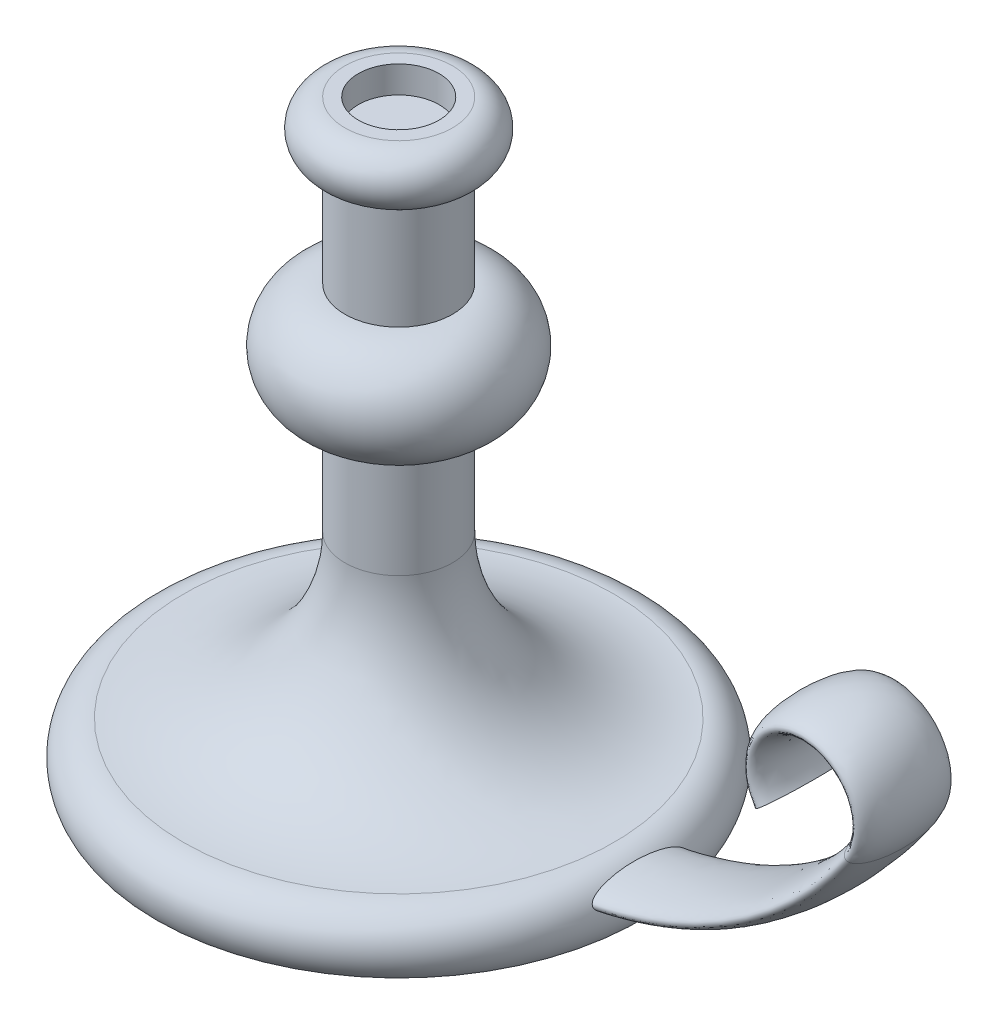
from build123d import *

# Parameters (mm, degrees)
SKETCH5_RX         = 17.5
SKETCH5_RY         = 5
SKETCH6_R          = 15
CUT_EXTRUDE1_DEPTH = 10


with BuildPart() as part:
    # Sketch1 → Revolve1 (revolve)
    with BuildSketch(Plane.XY):
        with BuildLine():
            Line((0, 0), (90, 0))
            ThreePointArc((90, 0), (91.180339887, 13.090169944), (80, 20))
            ThreePointArc((80, 20), (37.573593129, 37.573593129), (20, 80))
            Line((20, 80), (20, 120))
            ThreePointArc((20, 120), (40, 140), (20, 160))
            Line((20, 160), (20, 200))
            ThreePointArc((20, 200), (30, 210), (20, 220))
            Line((20, 220), (0, 220))
            Line((0, 220), (0, 0))
        make_face()
    revolve(axis=Axis((0, 0, 0), (0, 1, 0)))

    # Sweep1: sweep along a path in Sketch2
    with BuildLine(Plane.XY) as sweep1_path:
        Line((0, 10), (60, 10))
        ThreePointArc((60, 10), (129.821200219, 27.240819526), (183.592070943, 75))
        ThreePointArc((183.592070943, 75), (167.113128151, 106.333333333), (150.634185358, 75))
    # Sketch5 → Sweep1 (sweep)
    with BuildSketch(Plane(origin=(0, 0, 0), x_dir=(0, 0, -1), z_dir=(1, 0, 0))):
        with Locations(Location((0, 10), (0, 0, 180))):
            Ellipse(SKETCH5_RX, SKETCH5_RY)
    sweep(path=sweep1_path.line)

    # Sketch6 → Cut-Extrude1 (cut)
    with BuildSketch(Plane(origin=(0, 220, 0), x_dir=(1, 0, 0), z_dir=(0, 1, 0))):
        Circle(SKETCH6_R)
    extrude(amount=-CUT_EXTRUDE1_DEPTH, mode=Mode.SUBTRACT)


solid = part.part
